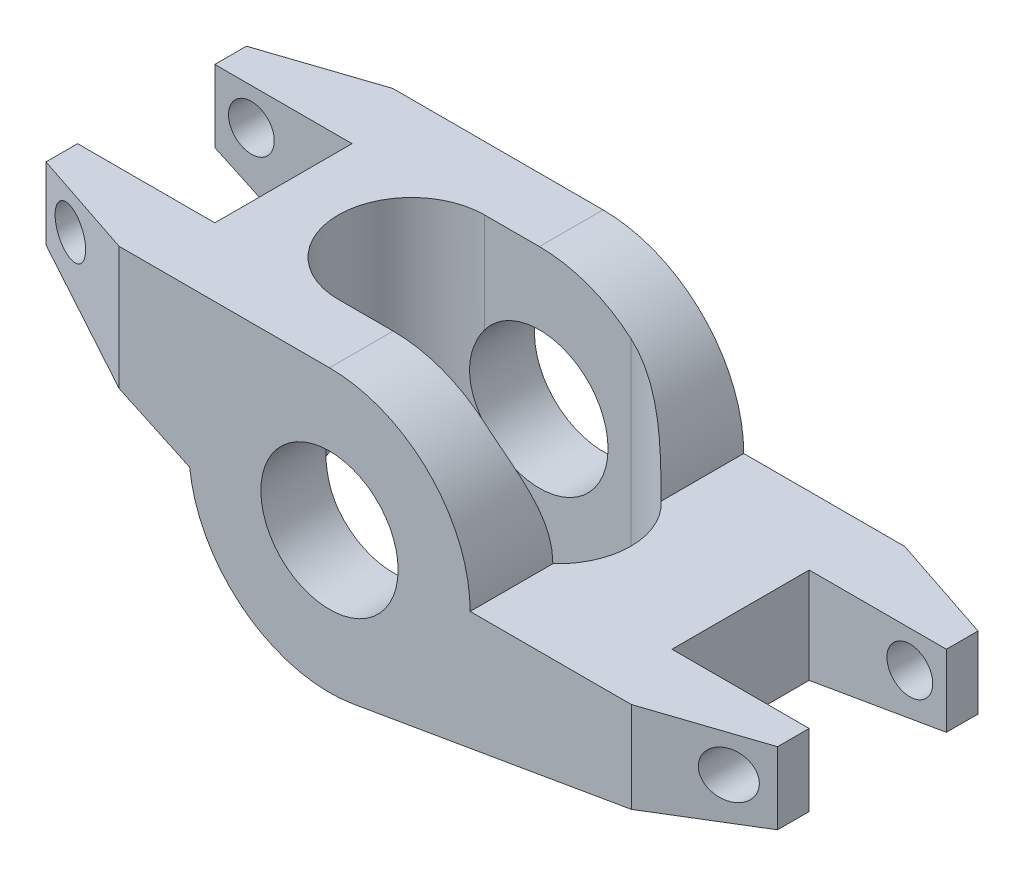
from build123d import *

# Parameters (mm, degrees)
SKETCH1_R               = 4.765
BOSS_EXTRUDE1_DEPTH     = 9.5
CHAMFER1_SIZE           = 7.62
CHAMFER1_SIZE2          = 2.54
CHAMFER2_SIZE           = 2.54
CHAMFER2_SIZE2          = 7.62
CHAMFER2_PART_2_SIZE    = 2.54
CHAMFER2_PART_2_SIZE2   = 7.62
SKETCH3_W               = 9.53
SKETCH3_H               = 9.53
CUT_EXTRUDE1_DEPTH      = 20.54
CUT_EXTRUDE2_DEPTH      = 10.77
CUT_EXTRUDE2_DEPTH_BACK = 10.77
SKETCH5_R               = 1.59
CUT_EXTRUDE3_DEPTH      = 10.5000001
CUT_EXTRUDE3_DEPTH_BACK = 10.5000001


with BuildPart() as part:
    # Sketch1 → Boss-Extrude1 (new body, symmetric)
    with BuildSketch(Plane.XY):
        with BuildLine():
            Line((0, 9.77), (-22.23, 9.77))
            Line((-22.23, 9.77), (-22.23, 4.77))
            Line((-22.23, 4.77), (-9.711509246, -1.067468107))
            ThreePointArc((-9.711509246, -1.067468107), (-5.877874817, -7.804068659), (1.655323868, -9.628748771))
            Line((1.655323868, -9.628748771), (28.58, -5))
            Line((28.58, -5), (28.58, 0))
            Line((28.58, 0), (9.77, 0))
            ThreePointArc((9.77, 0), (6.908433252, 6.908433252), (0, 9.77))
        make_face()
        Circle(SKETCH1_R, mode=Mode.SUBTRACT)
    extrude(amount=BOSS_EXTRUDE1_DEPTH, both=True)

    # Chamfer1
    chamfer1_edges = [part.edges().sort_by_distance(p)[0] for p in [
        (-22.23, 7.27, -9.5),
        (28.58, -2.5, -9.5),
    ]]
    chamfer1_side = [part.faces().sort_by_distance(p)[0] for p in [
        (-11.115, 9.225622585, -9.5),
    ]]
    chamfer(chamfer1_edges, length=CHAMFER1_SIZE, length2=CHAMFER1_SIZE2, reference=chamfer1_side[0])

    # Chamfer2
    chamfer2_edges = [part.edges().sort_by_distance(p)[0] for p in [
        (-22.23, 7.27, 9.5),
    ]]
    chamfer2_side = [part.faces().sort_by_distance(p)[0] for p in [
        (-22.23, 7.27, 1.27),
    ]]
    chamfer(chamfer2_edges, length=CHAMFER2_SIZE, length2=CHAMFER2_SIZE2, reference=chamfer2_side[0])

    # Chamfer2 part 2
    chamfer2_part_2_edges = [part.edges().sort_by_distance(p)[0] for p in [
        (28.58, -2.5, 9.5),
    ]]
    chamfer2_part_2_side = [part.faces().sort_by_distance(p)[0] for p in [
        (28.58, -2.5, 1.27),
    ]]
    chamfer(chamfer2_part_2_edges, length=CHAMFER2_PART_2_SIZE, length2=CHAMFER2_PART_2_SIZE2, reference=chamfer2_part_2_side[0])

    # Sketch3 → Cut-Extrude1 (cut, through all)
    with BuildSketch(Plane(origin=(0, 9.77, 0), x_dir=(1, 0, 0), z_dir=(0, 1, 0))):
        with Locations((-17.465, 0)):
            Rectangle(SKETCH3_W, SKETCH3_H)
        with Locations((23.815, 0)):
            Rectangle(SKETCH3_W, SKETCH3_H)
    extrude(amount=-CUT_EXTRUDE1_DEPTH, mode=Mode.SUBTRACT)

    # Sketch4 → Cut-Extrude2 (cut, two sides)
    with BuildSketch(Plane(origin=(0, 0, 0), x_dir=(1, 0, 0), z_dir=(0, 1, 0))) as cut_extrude2_sk:
        with BuildLine():
            Line((-3.81, 5.08), (6.35, 5.08))
            ThreePointArc((6.35, 5.08), (11.43, 0), (6.35, -5.08))
            Line((6.35, -5.08), (-3.81, -5.08))
            ThreePointArc((-3.81, -5.08), (-8.89, 0), (-3.81, 5.08))
        make_face()
    extrude(amount=CUT_EXTRUDE2_DEPTH, mode=Mode.SUBTRACT)
    extrude(cut_extrude2_sk.sketch, amount=-CUT_EXTRUDE2_DEPTH_BACK, mode=Mode.SUBTRACT)

    # Sketch5 → Cut-Extrude3 (cut, two sides)
    with BuildSketch(Plane.XY) as cut_extrude3_sk:
        with Locations((-19.69, 7.23)):
            Circle(SKETCH5_R)
        with Locations((26.04, -2.54)):
            Circle(SKETCH5_R)
    extrude(amount=CUT_EXTRUDE3_DEPTH, mode=Mode.SUBTRACT)
    extrude(cut_extrude3_sk.sketch, amount=-CUT_EXTRUDE3_DEPTH_BACK, mode=Mode.SUBTRACT)


solid = part.part
